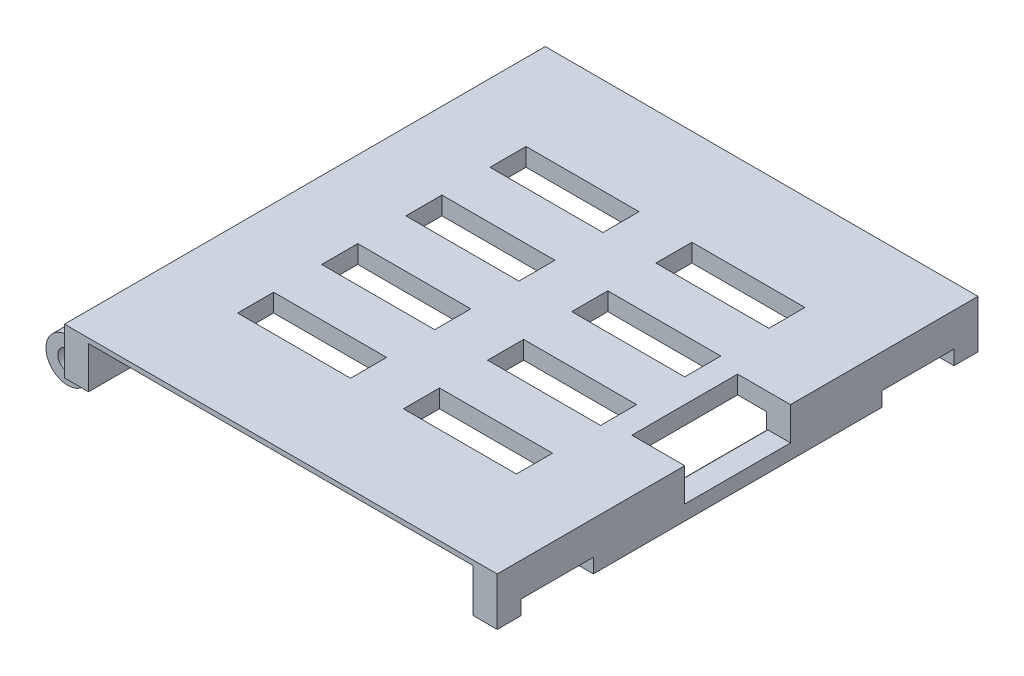
from build123d import *

# Parameters (mm, degrees)
BOSS_EXTRUDE1_DEPTH = 31.75
CUT_EXTRUDE1_DEPTH  = 6.985
SKETCH2_W           = 3.429
SKETCH2_H           = 10.222992
SKETCH2_W_2         = 43.942
CUT_EXTRUDE2_DEPTH  = 19.05
SKETCH4_W           = 14.9225
SKETCH4_H           = 4.7625
CUT_EXTRUDE4_DEPTH  = 48.499676787
CUT_EXTRUDE7_DEPTH  = 6.985
SKETCH9_W           = 50.8
SKETCH9_H           = 1.74625
CUT_EXTRUDE8_DEPTH  = 6.35
SKETCH10_W          = 9.525
SKETCH10_H          = 1.905
CUT_EXTRUDE9_DEPTH  = 1.905
SKETCH11_W          = 3.175
SKETCH11_H          = 0.1905
CUT_EXTRUDE10_DEPTH = 73.520592781
FILLET2_R           = 0.127


with BuildPart() as part:
    # Sketch1 → Boss-Extrude1 (new, symmetric)
    with BuildSketch(Plane.XY):
        with BuildLine():
            Line((-28.575, 6.35), (-30.257496, -0.999998))
            ThreePointArc((-30.257496, -0.999998), (-32.447762596, -1.986950865), (-31.736171426, 0.307603934))
            Line((-31.736171426, 0.307603934), (-31.926464573, 1.851416204))
            ThreePointArc((-31.926464573, 1.851416204), (-33.592921231, -3.045007588), (-28.719147778, -1.313425633))
            Line((-28.719147778, -1.313425633), (-28.575, 0))
            Line((-28.575, 0), (-25.4, 0))
            Line((-25.4, 0), (-25.4, 3.96875))
            Line((-25.4, 3.96875), (25.4, 3.96875))
            Line((25.4, 3.96875), (25.4, 0))
            Line((25.4, 0), (28.575, 0))
            Line((28.575, 0), (28.575, 6.35))
            Line((28.575, 6.35), (-28.575, 6.35))
        make_face()
    extrude(amount=BOSS_EXTRUDE1_DEPTH, both=True)

    # Sketch1_4 → Cut-Extrude1 (cut, symmetric)
    with BuildSketch(Plane.XY):
        Polygon((28.575, 6.35), (21.59, 6.35), (21.59, 3.96875), (25.4, 3.96875), (25.4, 1.9685), (28.575, 1.9685), align=None)
    extrude(amount=CUT_EXTRUDE1_DEPTH, both=True, mode=Mode.SUBTRACT)

    # Sketch2 → Cut-Extrude2 (cut)
    with BuildSketch(Plane(origin=(-28.575, 9.604995709, 0), x_dir=(0, 0, 1), z_dir=(-1, 0, 0))):
        with Locations((30.0355, -8.366491709)):
            Rectangle(SKETCH2_W, SKETCH2_H)
        with Locations((-30.0355, -8.366491709)):
            Rectangle(SKETCH2_W, SKETCH2_H)
        with Locations((0, -8.366491709)):
            Rectangle(SKETCH2_W_2, SKETCH2_H)
    extrude(amount=CUT_EXTRUDE2_DEPTH, mode=Mode.SUBTRACT)

    # Sketch4 → Cut-Extrude4 (cut, through all)
    with BuildSketch(Plane.XZ.offset(-3.96875)):
        with Locations((-10.95375, 16.66875)):
            Rectangle(SKETCH4_W, SKETCH4_H)
        with Locations((10.95375, 16.66875)):
            Rectangle(SKETCH4_W, SKETCH4_H)
        with Locations((-10.95375, 5.55625)):
            Rectangle(SKETCH4_W, SKETCH4_H)
        with Locations((10.95375, 5.55625)):
            Rectangle(SKETCH4_W, SKETCH4_H)
        with Locations((-10.95375, -5.55625)):
            Rectangle(SKETCH4_W, SKETCH4_H)
        with Locations((10.95375, -5.55625)):
            Rectangle(SKETCH4_W, SKETCH4_H)
        with Locations((-10.95375, -16.66875)):
            Rectangle(SKETCH4_W, SKETCH4_H)
        with Locations((10.95375, -16.66875)):
            Rectangle(SKETCH4_W, SKETCH4_H)
    extrude(amount=-CUT_EXTRUDE4_DEPTH, mode=Mode.SUBTRACT)

    # Sketch8 → Cut-Extrude7 (cut, symmetric)
    with BuildSketch(Plane.XY):
        with BuildLine():
            Line((25.4, 0), (27.432, 0))
            ThreePointArc((27.432, 0), (26.172949082, 0.772949082), (25.4, 2.032))
            Line((25.4, 2.032), (25.4, 0))
        make_face()
    extrude(amount=CUT_EXTRUDE7_DEPTH, both=True, mode=Mode.SUBTRACT)

    # Sketch9 → Cut-Extrude8 (cut)
    with BuildSketch(Plane.XY.offset(31.75)):
        with Locations((0, 4.841875)):
            Rectangle(SKETCH9_W, SKETCH9_H)
    cut_extrude8 = extrude(amount=-CUT_EXTRUDE8_DEPTH, mode=Mode.SUBTRACT)

    # Mirror1: Cut-Extrude8 across plane
    add(cut_extrude8.mirror(Plane.XY), mode=Mode.SUBTRACT)

    # Sketch10 → Cut-Extrude9 (cut)
    with BuildSketch(Plane(origin=(28.575, 0, 0), x_dir=(0, 0, -1), z_dir=(1, 0, 0))):
        with Locations((23.8125, 0.9525)):
            Rectangle(SKETCH10_W, SKETCH10_H)
        with Locations((-23.8125, 0.9525)):
            Rectangle(SKETCH10_W, SKETCH10_H)
    extrude(amount=-CUT_EXTRUDE9_DEPTH, mode=Mode.SUBTRACT)

    # Sketch11 → Cut-Extrude10 (cut, through all)
    with BuildSketch(Plane.XY.offset(31.75)):
        with Locations((-26.9875, 0.09525)):
            Rectangle(SKETCH11_W, SKETCH11_H)
    extrude(amount=-CUT_EXTRUDE10_DEPTH, mode=Mode.SUBTRACT)

    # Fillet2
    fillet2_edges = [part.edges().sort_by_distance(p)[0] for p in [
        (25.421490589, 1.9685, 0),
    ]]
    fillet(fillet2_edges, radius=FILLET2_R)


solid = part.part
